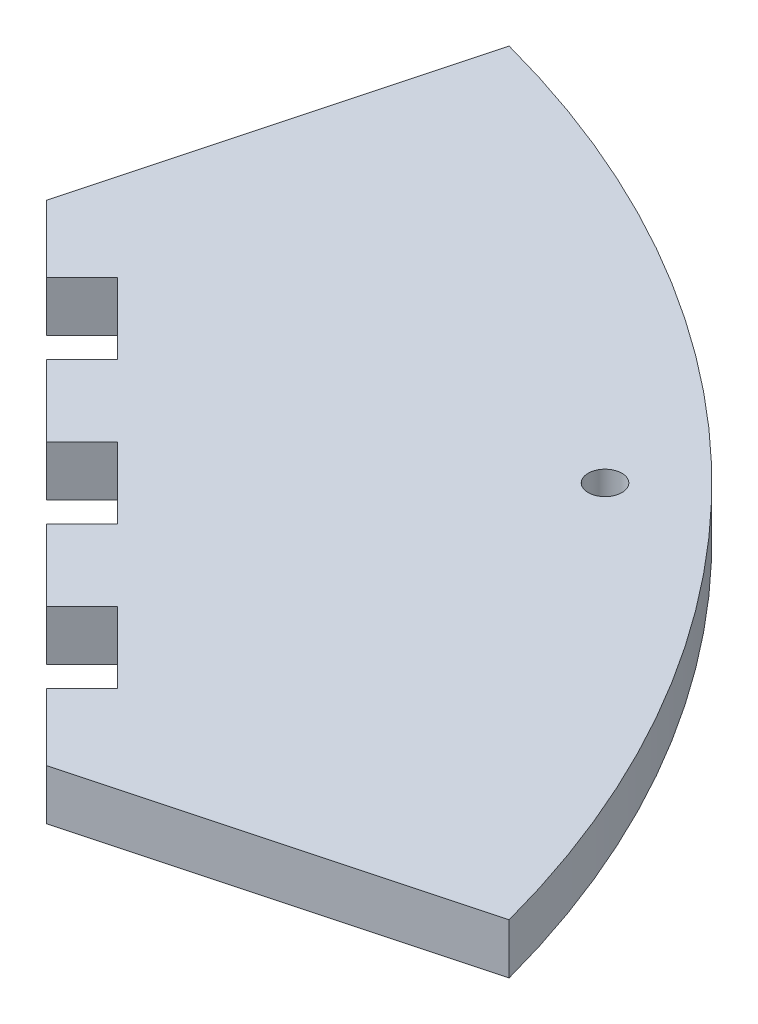
from build123d import *

# Parameters (mm, degrees)
BOSS_EXTRUDE1_DEPTH      = 5.08
M3_CLEARANCE_HOLE1_D     = 3.4
M3_CLEARANCE_HOLE1_DEPTH = 11.938
M3_CLEARANCE_HOLE1_TIP   = 1.021463052
CUT_EXTRUDE1_REACH       = 7.08


with BuildPart() as part:
    # Sketch1 → Boss-Extrude1 (new body)
    with BuildSketch(Plane(origin=(0, 0, 0), x_dir=(1, 0, 0), z_dir=(0, 1, 0))):
        with BuildLine():
            Line((27.939515919, 104.271692948), (18.0785103, 67.469918966))
            Line((18.0785103, 67.469918966), (67.469918966, 18.0785103))
            Line((67.469918966, 18.0785103), (104.271692948, 27.939515919))
            ThreePointArc((104.271692948, 27.939515919), (76.332177029, 76.332177029), (27.939515919, 104.271692948))
        make_face()
    extrude(amount=BOSS_EXTRUDE1_DEPTH)

    # M3 Clearance Hole1
    with Locations(Plane(origin=(0, 5.08, 0), x_dir=(1, 0, 0), z_dir=(0, 1, 0))):
        with Locations((70.944023356, 70.944023356)):
            Hole(M3_CLEARANCE_HOLE1_D / 2, depth=M3_CLEARANCE_HOLE1_DEPTH)
            with Locations((0, 0, -(M3_CLEARANCE_HOLE1_DEPTH + M3_CLEARANCE_HOLE1_TIP / 2))):  # 118° drill point
                Cone(0, M3_CLEARANCE_HOLE1_D / 2, M3_CLEARANCE_HOLE1_TIP, mode=Mode.SUBTRACT)

    # Sketch5 → Cut-Extrude1 (cut, up to next)
    with BuildSketch(Plane(origin=(0, 5.08, 0), x_dir=(1, 0, 0), z_dir=(0, 1, 0)), mode=Mode.PRIVATE) as cut_extrude1_sk1:
        Polygon((64.326829324, 28.40580484), (57.142624427, 35.590009736), (53.550521979, 31.997907288), (60.734726875, 24.813702391), align=None)
    cut_extrude1_tool1 = extrude(cut_extrude1_sk1.sketch, amount=-CUT_EXTRUDE1_REACH, mode=Mode.PRIVATE) & part.part
    add(cut_extrude1_tool1.solids().sort_by_distance((58.938676, 5.08, -30.201856))[0], mode=Mode.SUBTRACT)
    # Sketch5 → Cut-Extrude1 (cut, up to next)
    with BuildSketch(Plane(origin=(0, 5.08, 0), x_dir=(1, 0, 0), z_dir=(0, 1, 0)), mode=Mode.PRIVATE) as cut_extrude1_sk2:
        Polygon((49.95841953, 42.774214633), (42.774214633, 49.95841953), (39.182112185, 46.366317082), (46.366317082, 39.182112185), align=None)
    cut_extrude1_tool2 = extrude(cut_extrude1_sk2.sketch, amount=-CUT_EXTRUDE1_REACH, mode=Mode.PRIVATE) & part.part
    add(cut_extrude1_tool2.solids().sort_by_distance((44.570266, 5.08, -44.570266))[0], mode=Mode.SUBTRACT)
    # Sketch5 → Cut-Extrude1 (cut, up to next)
    with BuildSketch(Plane(origin=(0, 5.08, 0), x_dir=(1, 0, 0), z_dir=(0, 1, 0)), mode=Mode.PRIVATE) as cut_extrude1_sk3:
        Polygon((24.813702391, 60.734726875), (31.997907288, 53.550521979), (35.590009736, 57.142624427), (28.40580484, 64.326829324), align=None)
    cut_extrude1_tool3 = extrude(cut_extrude1_sk3.sketch, amount=-CUT_EXTRUDE1_REACH, mode=Mode.PRIVATE) & part.part
    add(cut_extrude1_tool3.solids().sort_by_distance((30.201856, 5.08, -58.938676))[0], mode=Mode.SUBTRACT)


solid = part.part
